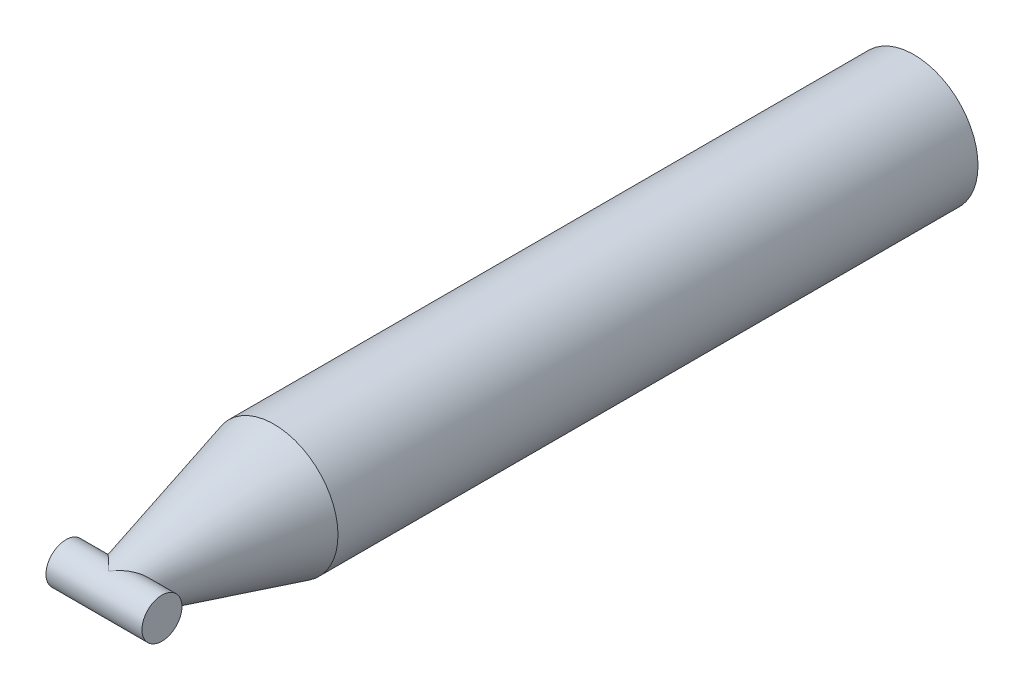
from build123d import *

# Parameters (mm, degrees)
BOSS_EXTRUDE1_DEPTH      = 6
BOSS_EXTRUDE1_DEPTH_BACK = 6
SKETCH3_R                = 2.5


with BuildPart() as part:
    # Sketch2 → Revolve1 (revolve)
    with BuildSketch(Plane(origin=(0, 0, 0), x_dir=(0, 0, -1), z_dir=(1, 0, 0))):
        with BuildLine():
            Line((50, 0), (50, 8))
            Line((50, 8), (-30, 8))
            Line((-30, 8), (-50.652805728, 2.413264321))
            ThreePointArc((-50.652805728, 2.413264321), (-51.985197008, 1.519537048), (-52.5, 0))
            Line((-52.5, 0), (50, 0))
        make_face()
    revolve(axis=Axis((0, 0, 50), (0, 0, -1)))

    # Sketch3 → Boss-Extrude1 (add, two sides: drawn at the far end of the back side and taken through both)
    with BuildSketch(Plane(origin=(0, 0, 0), x_dir=(0, 0, -1), z_dir=(1, 0, 0)).offset(-BOSS_EXTRUDE1_DEPTH_BACK)):
        with Locations((-50, 0)):
            Circle(SKETCH3_R)
    extrude(amount=BOSS_EXTRUDE1_DEPTH + BOSS_EXTRUDE1_DEPTH_BACK)


solid = part.part
